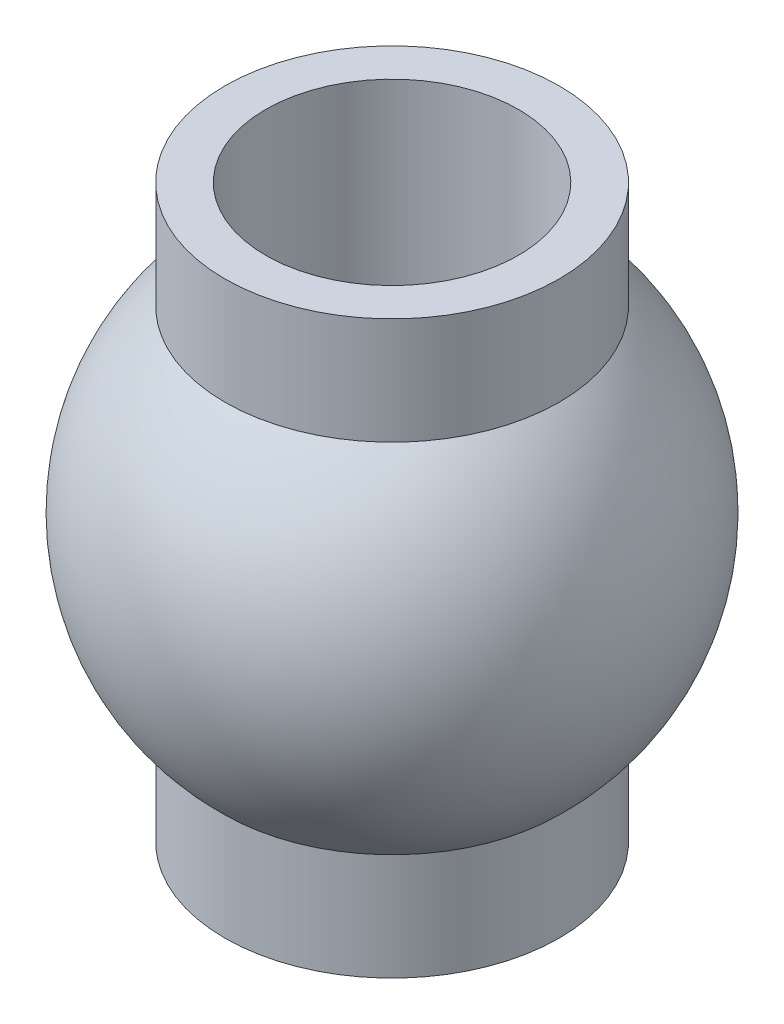
from build123d import *


with BuildPart() as part:
    # Sketch2 → Revolve1 (revolve)
    with BuildSketch(Plane.XY):
        with BuildLine():
            Line((1.55, 3.5), (1.55, -3.5))
            Line((1.55, -3.5), (2.05, -3.5))
            Line((2.05, -3.5), (2.05, -2.190319611))
            ThreePointArc((2.05, -2.190319611), (3, 0), (2.05, 2.190319611))
            Line((2.05, 2.190319611), (2.05, 3.5))
            Line((2.05, 3.5), (1.55, 3.5))
        make_face()
    revolve(axis=Axis((0, 3.5, 0), (0, -1, 0)))


solid = part.part
